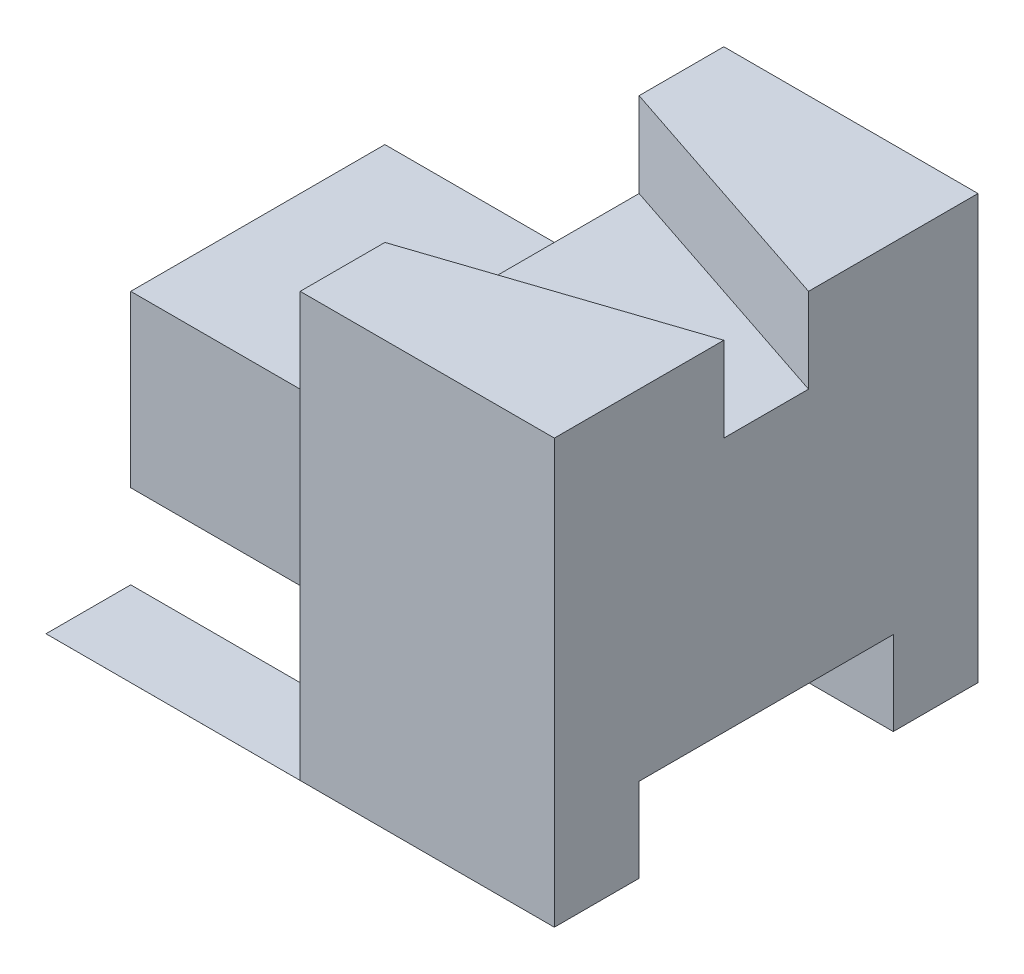
from build123d import *

# Parameters (mm, degrees)
SKETCH1_W               = 30
SKETCH1_H               = 50
BOSS_EXTRUDE1_DEPTH     = 50
SKETCH2_W               = 30
SKETCH2_H               = 20
BOSS_EXTRUDE2_DEPTH     = 30
SKETCH3_W               = 30
SKETCH3_H               = 20
CUT_EXTRUDE1_DEPTH      = 10
SKETCH4_W               = 30
SKETCH4_H               = 20
BOSS_EXTRUDE3_DEPTH     = 10
SKETCH6_W               = 30
SKETCH6_H               = 50
CUT_EXTRUDE2_DEPTH      = 10
BOSS_EXTRUDE6_DEPTH     = 30
SKETCH10_W              = 30
SKETCH10_H              = 10
BOSS_EXTRUDE8_DEPTH     = 5
SKETCH11_W              = 30
SKETCH11_H              = 10
BOSS_EXTRUDE9_DEPTH     = 5
BOSS_EXTRUDE10_DEPTH    = 10
BOSS_EXTRUDE11_DEPTH    = 10
CUT_EXTRUDE3_DEPTH      = 30
CUT_EXTRUDE3_DEPTH_BACK = 30
SKETCH14_W              = 30
SKETCH14_H              = 10
CUT_EXTRUDE4_DEPTH      = 20
SKETCH19_W              = 36.844767133
SKETCH19_H              = 14.176927822
BOSS_EXTRUDE18_DEPTH    = 10
SKETCH20_W              = 30
SKETCH20_H              = 10
BOSS_EXTRUDE19_DEPTH    = 10
SKETCH22_W              = 36.844767133
SKETCH22_H              = 14.176927822
CUT_EXTRUDE6_DEPTH      = 9.75
SKETCH25_W              = 36.844767133
SKETCH25_H              = 14.176927822
CUT_EXTRUDE14_DEPTH     = 0.12
SKETCH26_W              = 36.844767133
SKETCH26_H              = 14.176927822
CUT_EXTRUDE15_DEPTH     = 0.12
SKETCH29_W              = 36.844767133
SKETCH29_H              = 14.176927822
BOSS_EXTRUDE21_DEPTH    = 0.05
SKETCH31_W              = 60
SKETCH31_H              = 30
BOSS_EXTRUDE25_DEPTH    = 0.08
SKETCH32_W              = 30
SKETCH32_H              = 10
CUT_EXTRUDE22_DEPTH     = 10
SKETCH38_W              = 10
SKETCH38_H              = 9.92
CUT_EXTRUDE26_DEPTH     = 0.001
SKETCH39_W              = 30
SKETCH39_H              = 10
BOSS_EXTRUDE31_DEPTH    = 0.001


with BuildPart() as part:
    # Sketch1 → Boss-Extrude1 (new body)
    with BuildSketch(Plane.XY):
        with Locations((15, 25)):
            Rectangle(SKETCH1_W, SKETCH1_H)
    extrude(amount=BOSS_EXTRUDE1_DEPTH)

    # Sketch2 → Boss-Extrude2 (add)
    with BuildSketch(Plane.XY.offset(50)):
        with Locations((-15, 20)):
            Rectangle(SKETCH2_W, SKETCH2_H)
    extrude(amount=-BOSS_EXTRUDE2_DEPTH)

    # Sketch3 → Cut-Extrude1 (cut)
    with BuildSketch(Plane.XY.offset(50)):
        with Locations((-15, 20)):
            Rectangle(SKETCH3_W, SKETCH3_H)
    extrude(amount=-CUT_EXTRUDE1_DEPTH, mode=Mode.SUBTRACT)

    # Sketch4 → Boss-Extrude3 (add)
    with BuildSketch(Plane(origin=(0, 0, 20), x_dir=(-1, 0, 0), z_dir=(0, 0, -1))):
        with Locations((15, 20)):
            Rectangle(SKETCH4_W, SKETCH4_H)
    extrude(amount=BOSS_EXTRUDE3_DEPTH)

    # Sketch6 → Cut-Extrude2 (cut)
    with BuildSketch(Plane(origin=(0, 50, 0), x_dir=(1, 0, 0), z_dir=(0, 1, 0))):
        with Locations((15, -25)):
            Rectangle(SKETCH6_W, SKETCH6_H)
    extrude(amount=-CUT_EXTRUDE2_DEPTH, mode=Mode.SUBTRACT)

    # Sketch9 → Boss-Extrude6 (add)
    with BuildSketch(Plane.XY.offset(30)):
        Polygon((-30, 0), (0, 0), (0, 40), align=None)
    extrude(amount=-BOSS_EXTRUDE6_DEPTH)

    # Sketch10 → Boss-Extrude8 (add)
    with BuildSketch(Plane.XY.offset(50)):
        with Locations((15, 45)):
            Rectangle(SKETCH10_W, SKETCH10_H)
    extrude(amount=-BOSS_EXTRUDE8_DEPTH)

    # Sketch11 → Boss-Extrude9 (add)
    with BuildSketch(Plane(origin=(0, 0, 45), x_dir=(-1, 0, 0), z_dir=(0, 0, -1))):
        with Locations((-15, 45)):
            Rectangle(SKETCH11_W, SKETCH11_H)
    extrude(amount=BOSS_EXTRUDE9_DEPTH)

    # Sketch12 → Boss-Extrude10 (add)
    with BuildSketch(Plane(origin=(0, 40, 0), x_dir=(1, 0, 0), z_dir=(0, 1, 0))):
        Polygon((0, -40), (30, -30), (30, -40), align=None)
    extrude(amount=BOSS_EXTRUDE10_DEPTH)

    # Sketch13 → Boss-Extrude11 (add)
    with BuildSketch(Plane(origin=(0, 40, 0), x_dir=(1, 0, 0), z_dir=(0, 1, 0))):
        Polygon((0, 0), (30, 0), (30, -20), (0, -10), align=None)
    extrude(amount=BOSS_EXTRUDE11_DEPTH)

    # Sketch14 → Cut-Extrude3 (cut, two sides: drawn at the far end of the back side and taken through both)
    with BuildSketch(Plane(origin=(0, 0, 0), x_dir=(0, 0, -1), z_dir=(1, 0, 0)).offset(-CUT_EXTRUDE3_DEPTH_BACK)):
        with Locations((-25, 5)):
            Rectangle(SKETCH14_W, SKETCH14_H)
    extrude(amount=CUT_EXTRUDE3_DEPTH + CUT_EXTRUDE3_DEPTH_BACK, mode=Mode.SUBTRACT)

    # Sketch15 → Cut-Extrude4 (cut)
    with BuildSketch(Plane.XY.offset(30)):
        Polygon((-7.5, 30), (0, 30), (0, 40), align=None)
    extrude(amount=-CUT_EXTRUDE4_DEPTH, mode=Mode.SUBTRACT)

    # Sketch19 → Boss-Extrude18 (add)
    with BuildSketch(Plane(origin=(0, 10, 0), x_dir=(-1, 0, 0), z_dir=(0, -1, 0))):
        with Locations((11.577616434, -32.911536089)):
            Rectangle(SKETCH19_W, SKETCH19_H)
    extrude(amount=BOSS_EXTRUDE18_DEPTH)

    # Sketch20 → Boss-Extrude19 (add)
    with BuildSketch(Plane.XY.offset(50)):
        with Locations((-15, 5)):
            Rectangle(SKETCH20_W, SKETCH20_H)
    extrude(amount=-BOSS_EXTRUDE19_DEPTH)

    # Sketch22 → Cut-Extrude6 (cut)
    with BuildSketch(Plane(origin=(0, 0, 0), x_dir=(-1, 0, 0), z_dir=(0, -1, 0))):
        with Locations((11.577616434, -32.911536089)):
            Rectangle(SKETCH22_W, SKETCH22_H)
    extrude(amount=-CUT_EXTRUDE6_DEPTH, mode=Mode.SUBTRACT)

    # Sketch25 → Cut-Extrude14 (cut)
    with BuildSketch(Plane(origin=(0, 9.75, 0), x_dir=(-1, 0, 0), z_dir=(0, -1, 0))):
        with Locations((11.577616434, -32.911536089)):
            Rectangle(SKETCH25_W, SKETCH25_H)
    extrude(amount=-CUT_EXTRUDE14_DEPTH, mode=Mode.SUBTRACT)

    # Sketch26 → Cut-Extrude15 (cut)
    with BuildSketch(Plane.XZ.offset(-9.87)):
        with Locations((-11.577616434, 32.911536089)):
            Rectangle(SKETCH26_W, SKETCH26_H)
    extrude(amount=-CUT_EXTRUDE15_DEPTH, mode=Mode.SUBTRACT)

    # Sketch29 → Boss-Extrude21 (add)
    with BuildSketch(Plane.XZ.offset(-10)):
        with Locations((-11.577616434, 32.911536089)):
            Rectangle(SKETCH29_W, SKETCH29_H)
    extrude(amount=BOSS_EXTRUDE21_DEPTH)

    # Sketch31 → Boss-Extrude25 (add)
    with BuildSketch(Plane(origin=(0, 10, 0), x_dir=(-1, 0, 0), z_dir=(0, -1, 0))):
        with Locations((0, -25)):
            Rectangle(SKETCH31_W, SKETCH31_H)
    extrude(amount=BOSS_EXTRUDE25_DEPTH)

    # Sketch32 → Cut-Extrude22 (cut)
    with BuildSketch(Plane.XY.offset(50)):
        with Locations((-15, 5)):
            Rectangle(SKETCH32_W, SKETCH32_H)
    extrude(amount=-CUT_EXTRUDE22_DEPTH, mode=Mode.SUBTRACT)

    # Sketch38 → Cut-Extrude26 (cut)
    with BuildSketch(Plane.ZY):
        with Locations((45, 4.96)):
            Rectangle(SKETCH38_W, SKETCH38_H)
    extrude(amount=-CUT_EXTRUDE26_DEPTH, mode=Mode.SUBTRACT)

    # Sketch39 → Boss-Extrude31 (add)
    with BuildSketch(Plane(origin=(0, 0, 0), x_dir=(-1, 0, 0), z_dir=(0, -1, 0))):
        with Locations((14.999, -45)):
            Rectangle(SKETCH39_W, SKETCH39_H)
    extrude(amount=-BOSS_EXTRUDE31_DEPTH)


solid = part.part
